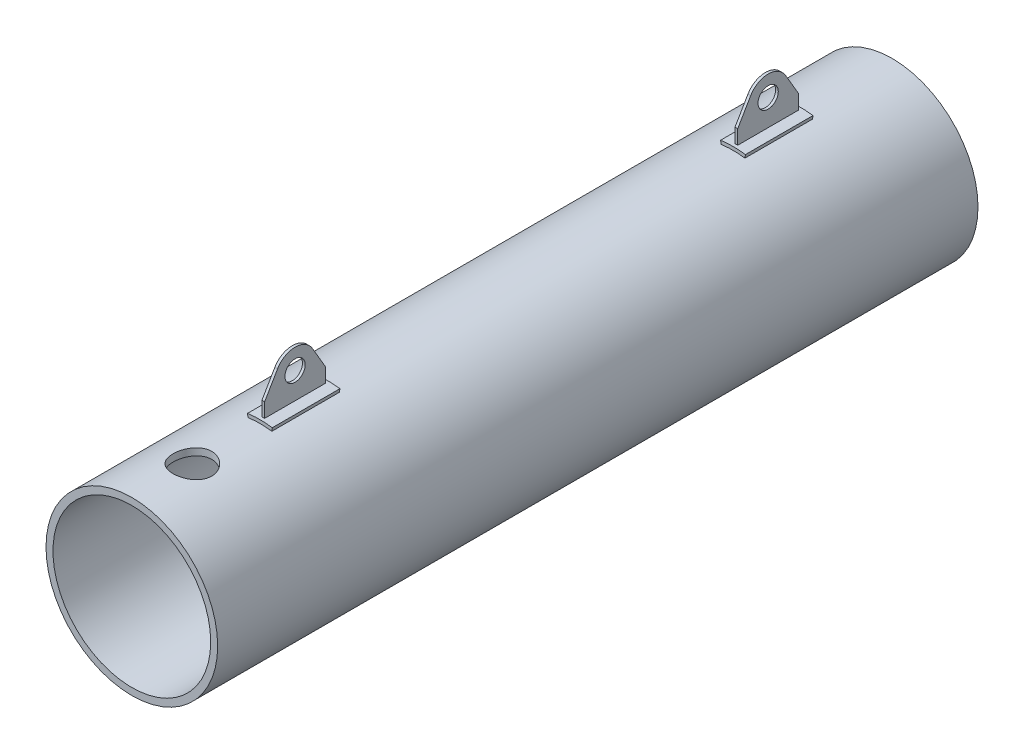
from build123d import *

# Parameters (mm, degrees)
SKETCH1_R           = 254
SKETCH1_R_2         = 233.38
BOSS_EXTRUDE1_DEPTH = 2250
CUT_EXTRUDE1_REACH  = 256
SKETCH2_R           = 57.25
CUT_EXTRUDE2_REACH  = 256
SKETCH3_R           = 57.25
CUT_EXTRUDE3_REACH  = 256
SKETCH4_R           = 24.5
SKETCH5_W           = 200
SKETCH5_H           = 10
REVOLVE1_ANGLE      = 16
SKETCH6_R           = 30
BOSS_EXTRUDE2_DEPTH = 4


with BuildPart() as part:
    # Sketch1 → Boss-Extrude1 (new body)
    with BuildSketch(Plane.XY):
        Circle(SKETCH1_R)
        Circle(SKETCH1_R_2, mode=Mode.SUBTRACT)
    extrude(amount=-BOSS_EXTRUDE1_DEPTH)

    # Sketch2 → Cut-Extrude1 (cut, up to next)
    with BuildSketch(Plane(origin=(0, 0, 0), x_dir=(1, 0, 0), z_dir=(0, 1, 0)), mode=Mode.PRIVATE) as cut_extrude1_sk1:
        with Locations((0, 179)):
            Circle(SKETCH2_R)
    cut_extrude1_tool1 = extrude(cut_extrude1_sk1.sketch, amount=CUT_EXTRUDE1_REACH, mode=Mode.PRIVATE) & part.part
    add(cut_extrude1_tool1.solids().sort_by_distance((0, 0, -179))[0], mode=Mode.SUBTRACT)

    # Sketch3 → Cut-Extrude2 (cut, up to next)
    with BuildSketch(Plane(origin=(0, 0, 0), x_dir=(1, 0, 0), z_dir=(0, 1, 0)), mode=Mode.PRIVATE) as cut_extrude2_sk1:
        with Locations((0, 2049)):
            Circle(SKETCH3_R)
    cut_extrude2_tool1 = extrude(cut_extrude2_sk1.sketch, amount=-CUT_EXTRUDE2_REACH, mode=Mode.PRIVATE) & part.part
    add(cut_extrude2_tool1.solids().sort_by_distance((0, 0, -2049))[0], mode=Mode.SUBTRACT)

    # Sketch4 → Cut-Extrude3 (cut, up to next)
    with BuildSketch(Plane(origin=(0, 0, 0), x_dir=(1, 0, 0), z_dir=(0, 1, 0)), mode=Mode.PRIVATE) as cut_extrude3_sk1:
        with Locations((0, 649)):
            Circle(SKETCH4_R)
    cut_extrude3_tool1 = extrude(cut_extrude3_sk1.sketch, amount=-CUT_EXTRUDE3_REACH, mode=Mode.PRIVATE) & part.part
    add(cut_extrude3_tool1.solids().sort_by_distance((0, 0, -649))[0], mode=Mode.SUBTRACT)

    # Sketch5 → Revolve1 (revolve, symmetric)
    with BuildSketch(Plane(origin=(0, 0, 0), x_dir=(0, 0, -1), z_dir=(1, 0, 0))) as revolve1_sk:
        with Locations((479, 259)):
            Rectangle(SKETCH5_W, SKETCH5_H)
        with Locations((1879, 259)):
            Rectangle(SKETCH5_W, SKETCH5_H)
    revolve(axis=Axis((0, 0, 0), (0, 0, -1)), revolution_arc=REVOLVE1_ANGLE / 2)
    revolve(revolve1_sk.sketch, axis=Axis((0, 0, 0), (0, 0, 1)), revolution_arc=REVOLVE1_ANGLE / 2)

    # Sketch6 → Boss-Extrude2 (add, symmetric)
    with BuildSketch(Plane(origin=(0, 0, 0), x_dir=(0, 0, -1), z_dir=(1, 0, 0))):
        with BuildLine():
            Line((479, 251.52808946), (569, 251.52808946))
            Line((569, 251.52808946), (569, 306.52808946))
            Line((569, 306.52808946), (530.784861392, 371.832018754))
            ThreePointArc((530.784861392, 371.832018754), (479, 401.52808946), (427.215138608, 371.832018754))
            Line((427.215138608, 371.832018754), (389, 306.52808946))
            Line((389, 306.52808946), (389, 251.52808946))
            Line((389, 251.52808946), (479, 251.52808946))
        make_face()
        with Locations((479, 341.52808946)):
            Circle(SKETCH6_R, mode=Mode.SUBTRACT)
        with BuildLine():
            Line((1969, 251.52808946), (1969, 306.52808946))
            Line((1969, 306.52808946), (1930.784861392, 371.832018754))
            ThreePointArc((1930.784861392, 371.832018754), (1879, 401.52808946), (1827.215138608, 371.832018754))
            Line((1827.215138608, 371.832018754), (1789, 306.52808946))
            Line((1789, 306.52808946), (1789, 251.52808946))
            Line((1789, 251.52808946), (1879, 251.52808946))
            Line((1879, 251.52808946), (1969, 251.52808946))
        make_face()
        with Locations((1879, 341.52808946)):
            Circle(SKETCH6_R, mode=Mode.SUBTRACT)
    extrude(amount=BOSS_EXTRUDE2_DEPTH, both=True)


solid = part.part
